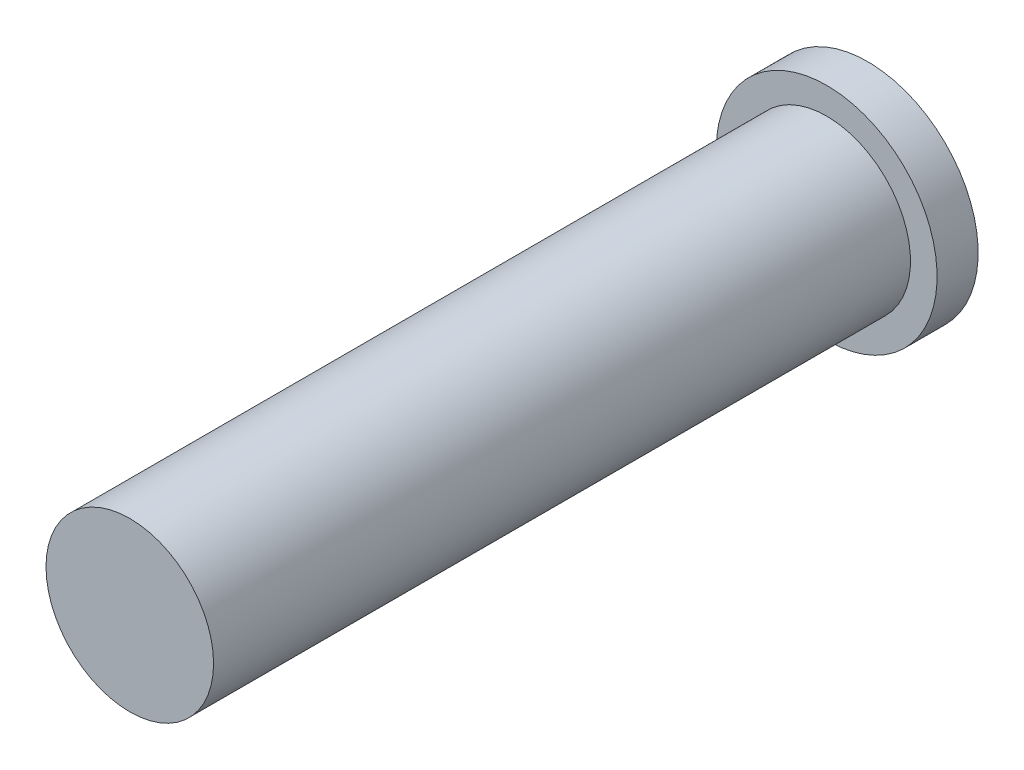
from build123d import *

# Parameters (mm, degrees)
SKETCH1_R           = 0.755
BOSS_EXTRUDE1_DEPTH = 6.28
SKETCH2_R           = 0.995
BOSS_EXTRUDE2_DEPTH = 0.37
SKETCH3_R           = 0.58
CUT_EXTRUDE1_DEPTH  = 6


with BuildPart() as part:
    # Sketch1 → Boss-Extrude1 (new body)
    with BuildSketch(Plane.XY):
        Circle(SKETCH1_R)
    extrude(amount=BOSS_EXTRUDE1_DEPTH)

    # Sketch2 → Boss-Extrude2 (add)
    with BuildSketch(Plane(origin=(0, 0, 0), x_dir=(-1, 0, 0), z_dir=(0, 0, -1))):
        Circle(SKETCH2_R)
    extrude(amount=BOSS_EXTRUDE2_DEPTH)

    # Sketch3 → Cut-Extrude1 (cut)
    with BuildSketch(Plane(origin=(0, 0, -0.37), x_dir=(-1, 0, 0), z_dir=(0, 0, -1))):
        Circle(SKETCH3_R)
    extrude(amount=-CUT_EXTRUDE1_DEPTH, mode=Mode.SUBTRACT)


solid = part.part
